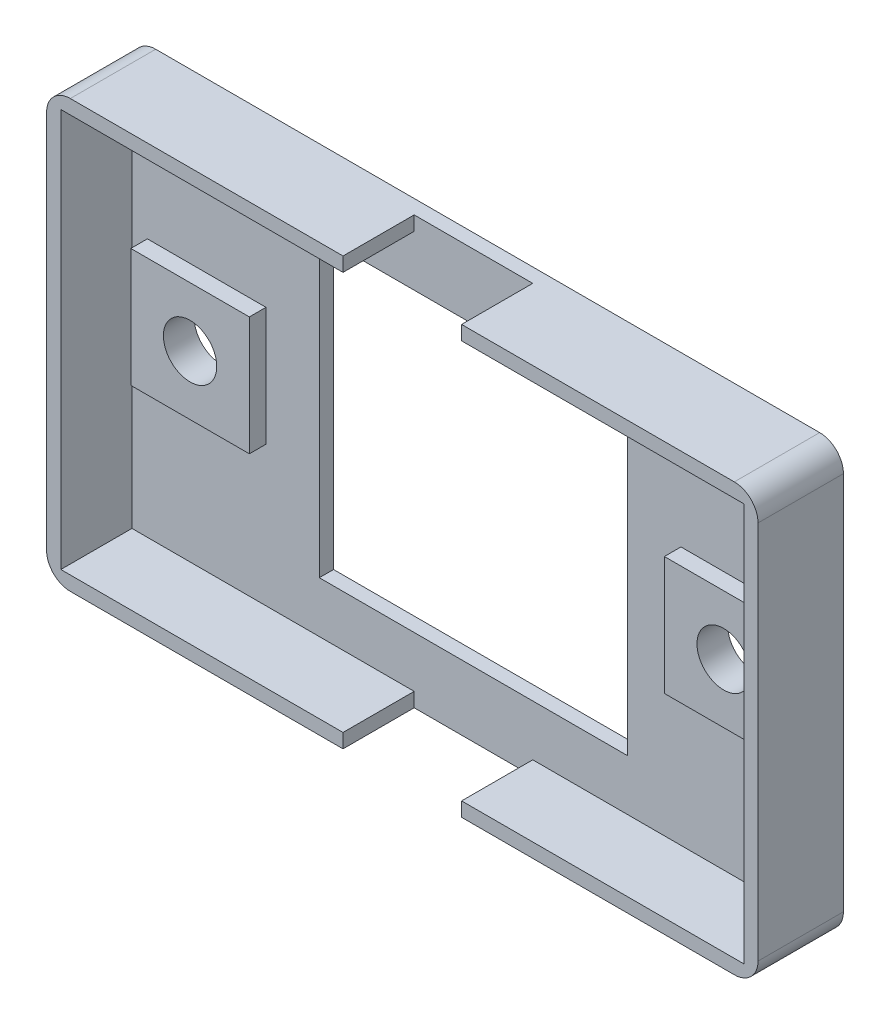
from build123d import *

# Parameters (mm, degrees)
SKICA1_W                = 60
SKICA1_H                = 36
SKICA1_W_2              = 26
SKICA1_H_2              = 25
P_IDAT_VYSUNUT_M1_DEPTH = 1.2
SKICA2_W                = 10
SKICA2_H                = 10
P_IDAT_VYSUNUT_M2_DEPTH = 1.4
P_IDAT_VYSUNUT_M3_DEPTH = 6
M4_D_RA_S_V_L_1_D       = 4.5
ZAOBLIT1_R              = 2


with BuildPart() as part:
    # Skica1 → Přidat vysunutím1 (new body)
    with BuildSketch(Plane.XY):
        Rectangle(SKICA1_W, SKICA1_H)
        Rectangle(SKICA1_W_2, SKICA1_H_2, mode=Mode.SUBTRACT)
    extrude(amount=P_IDAT_VYSUNUT_M1_DEPTH)

    # Skica2 → Přidat vysunutím2 (add)
    with BuildSketch(Plane.XY.offset(1.2)):
        with Locations((22.5, 0)):
            Rectangle(SKICA2_W, SKICA2_H)
        with Locations((-22.5, 0)):
            Rectangle(SKICA2_W, SKICA2_H)
    extrude(amount=P_IDAT_VYSUNUT_M2_DEPTH)

    # Skica3 → Přidat vysunutím3 (add)
    with BuildSketch(Plane.XY.offset(1.2)):
        Polygon((-28.8, -16.8), (-28.8, 16.8), (-5, 16.8), (-5, 18), (-30, 18), (-30, -18), (-5, -18), (-5, -16.8), align=None)
        Polygon((28.8, -16.8), (5, -16.8), (5, -18), (30, -18), (30, 18), (5, 18), (5, 16.8), (28.8, 16.8), align=None)
    extrude(amount=P_IDAT_VYSUNUT_M3_DEPTH)

    # M4 díra s vůlí1 (through all)
    with Locations(Plane.XY.offset(2.6)):
        with Locations((-22.5, 0), (22.5, 0)):
            Hole(M4_D_RA_S_V_L_1_D / 2)

    # Zaoblit1
    zaoblit1_edges = [part.edges().sort_by_distance(p)[0] for p in [
        (30, -18, 3.6),
        (-30, -18, 3.6),
        (-30, 18, 3.6),
        (30, 18, 3.6),
    ]]
    fillet(zaoblit1_edges, radius=ZAOBLIT1_R)


solid = part.part
